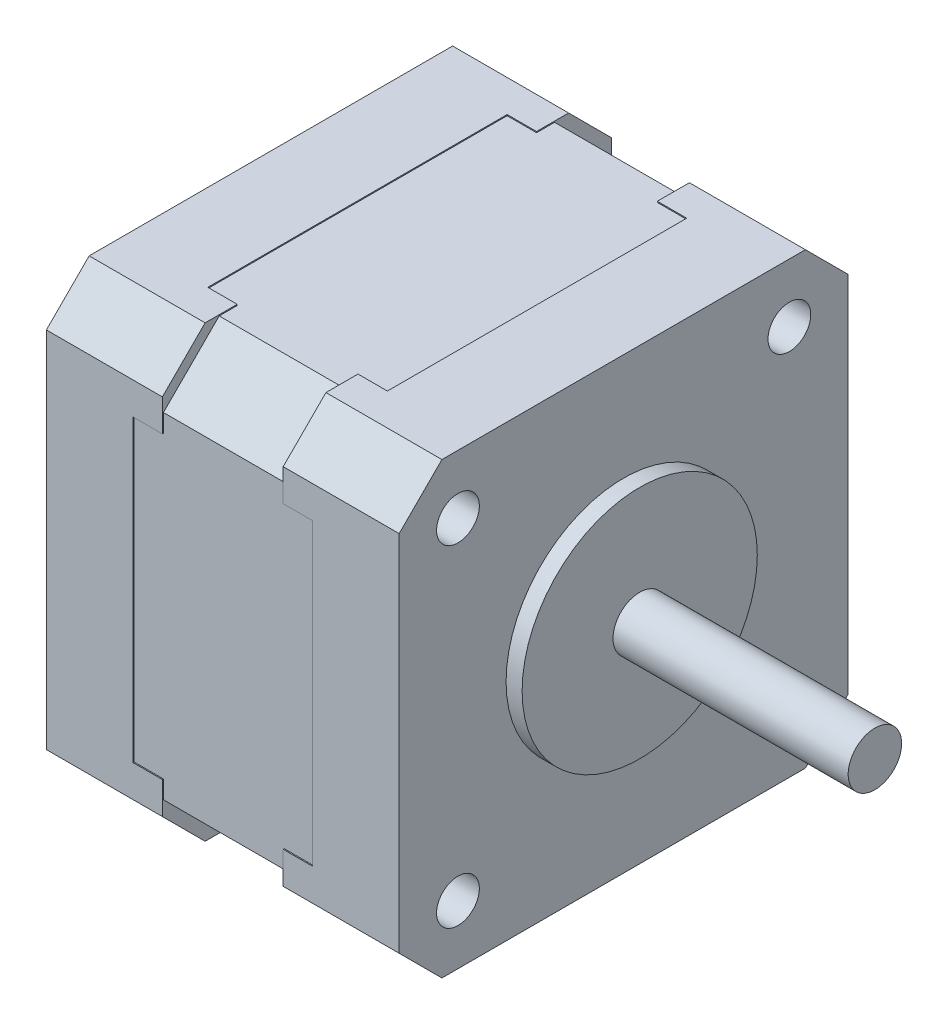
from build123d import *

# Parameters (mm, degrees)
CROQUIS1_W                  = 41.8
CROQUIS1_H                  = 41.8
SALIENTE_EXTRUIR1_DEPTH     = 11.3
CROQUIS2_W                  = 42
CROQUIS2_H                  = 41.9
SALIENTE_EXTRUIR2_DEPTH     = 10.85
CROQUIS3_W                  = 10.85
CROQUIS3_H                  = 42
SALIENTE_EXTRUIR3_DEPTH     = 0.1
CROQUIS4_W                  = 42
CROQUIS4_H                  = 42
SALIENTE_EXTRUIR4_DEPTH     = 10.85
CORTAR_EXTRUIR1_REACH       = 26.9
CROQUIS5_W                  = 0.1
CROQUIS5_H                  = 28
CORTAR_EXTRUIR2_REACH       = 26.9
CROQUIS6_W                  = 28
CROQUIS6_H                  = 0.1
CROQUIS7_W                  = 2.75
CROQUIS7_H                  = 28
CORTAR_EXTRUIR3_DEPTH       = 0.1
CROQUIS8_W                  = 2.75
CROQUIS8_H                  = 28
CORTAR_EXTRUIR4_DEPTH       = 0.1
CROQUIS9_W                  = 28
CROQUIS9_H                  = 0.1
CORTAR_EXTRUIR5_DEPTH       = 2.75
CROQUIS10_W                 = 2.75
CROQUIS10_H                 = 28
CORTAR_EXTRUIR6_DEPTH       = 0.1
CROQUIS11_W                 = 2.75
CROQUIS11_H                 = 28
CORTAR_EXTRUIR7_DEPTH       = 0.1
CROQUIS12_W                 = 2.75
CROQUIS12_H                 = 28
CORTAR_EXTRUIR8_DEPTH       = 0.1
CHAFL_N1_SIZE               = 5.214213562
CHAFL_N2_SIZE               = 4
CROQUIS18_R                 = 2
CORTAR_EXTRUIR10_DEPTH      = 6
CORTAR_EXTRUIR10_DEPTH_BACK = 3


with BuildPart() as part:
    # Croquis1 → Saliente-Extruir1 (new body)
    with BuildSketch(Plane(origin=(-5.65, 0, 0), x_dir=(0, -1, 0), z_dir=(-1, 0, 0))):
        Rectangle(CROQUIS1_W, CROQUIS1_H)
    extrude(amount=-SALIENTE_EXTRUIR1_DEPTH)

    # Croquis2 → Saliente-Extruir2 (add)
    with BuildSketch(Plane(origin=(5.65, 0, 0), x_dir=(0, 0, -1), z_dir=(1, 0, 0))):
        with Locations((0, -0.05)):
            Rectangle(CROQUIS2_W, CROQUIS2_H)
    extrude(amount=SALIENTE_EXTRUIR2_DEPTH)

    # Croquis3 → Saliente-Extruir3 (add)
    with BuildSketch(Plane(origin=(0, 20.9, 0), x_dir=(-1, 0, 0), z_dir=(0, 1, 0))):
        with Locations((-11.075, 0)):
            Rectangle(CROQUIS3_W, CROQUIS3_H)
    extrude(amount=SALIENTE_EXTRUIR3_DEPTH)

    # Croquis4 → Saliente-Extruir4 (add)
    with BuildSketch(Plane(origin=(-5.65, 0, 0), x_dir=(0, 0, -1), z_dir=(1, 0, 0))):
        Rectangle(CROQUIS4_W, CROQUIS4_H)
    extrude(amount=-SALIENTE_EXTRUIR4_DEPTH)

    # Croquis5 → Cortar-Extruir1 (cut, up to next)
    with BuildSketch(Plane(origin=(8.4, 0, 0), x_dir=(0, 0, -1), z_dir=(1, 0, 0)), mode=Mode.PRIVATE) as cortar_extruir1_sk1:
        with Locations((20.95, 0)):
            Rectangle(CROQUIS5_W, CROQUIS5_H)
    cortar_extruir1_tool1 = extrude(cortar_extruir1_sk1.sketch, amount=-CORTAR_EXTRUIR1_REACH, mode=Mode.PRIVATE) & part.part
    add(cortar_extruir1_tool1.solids().sort_by_distance((8.4, 0, -20.95))[0], mode=Mode.SUBTRACT)

    # Croquis6 → Cortar-Extruir2 (cut, up to next)
    with BuildSketch(Plane(origin=(-8.4, 0, 0), x_dir=(0, -1, 0), z_dir=(-1, 0, 0)), mode=Mode.PRIVATE) as cortar_extruir2_sk1:
        with Locations((0, 20.95)):
            Rectangle(CROQUIS6_W, CROQUIS6_H)
    cortar_extruir2_tool1 = extrude(cortar_extruir2_sk1.sketch, amount=-CORTAR_EXTRUIR2_REACH, mode=Mode.PRIVATE) & part.part
    add(cortar_extruir2_tool1.solids().sort_by_distance((-8.4, 0, 20.95))[0], mode=Mode.SUBTRACT)

    # Croquis7 → Cortar-Extruir3 (cut)
    with BuildSketch(Plane.XZ.offset(21)):
        with Locations((7.025, 0)):
            Rectangle(CROQUIS7_W, CROQUIS7_H)
    extrude(amount=-CORTAR_EXTRUIR3_DEPTH, mode=Mode.SUBTRACT)

    # Croquis8 → Cortar-Extruir4 (cut)
    with BuildSketch(Plane.XY.offset(21)):
        with Locations((7.025, 0)):
            Rectangle(CROQUIS8_W, CROQUIS8_H)
    extrude(amount=-CORTAR_EXTRUIR4_DEPTH, mode=Mode.SUBTRACT)

    # Croquis9 → Cortar-Extruir5 (cut)
    with BuildSketch(Plane.ZY.offset(-5.65)):
        with Locations((0, 20.95)):
            Rectangle(CROQUIS9_W, CROQUIS9_H)
    extrude(amount=-CORTAR_EXTRUIR5_DEPTH, mode=Mode.SUBTRACT)

    # Croquis10 → Cortar-Extruir6 (cut)
    with BuildSketch(Plane.XZ.offset(21)):
        with Locations((-7.025, 0)):
            Rectangle(CROQUIS10_W, CROQUIS10_H)
    extrude(amount=-CORTAR_EXTRUIR6_DEPTH, mode=Mode.SUBTRACT)

    # Croquis11 → Cortar-Extruir7 (cut)
    with BuildSketch(Plane(origin=(0, 0, -21), x_dir=(-1, 0, 0), z_dir=(0, 0, -1))):
        with Locations((7.025, 0)):
            Rectangle(CROQUIS11_W, CROQUIS11_H)
    extrude(amount=-CORTAR_EXTRUIR7_DEPTH, mode=Mode.SUBTRACT)

    # Croquis12 → Cortar-Extruir8 (cut)
    with BuildSketch(Plane(origin=(0, 21, 0), x_dir=(-1, 0, 0), z_dir=(0, 1, 0))):
        with Locations((7.025, 0)):
            Rectangle(CROQUIS12_W, CROQUIS12_H)
    extrude(amount=-CORTAR_EXTRUIR8_DEPTH, mode=Mode.SUBTRACT)

    # Croquis15 → Revolución1 (revolve)
    with BuildSketch(Plane.XY):
        Polygon((15.5, 11), (15.5, 0), (40, 0), (40, 2.5), (18, 2.5), (18, 11), align=None)
    revolve(axis=Axis((15.5, 0, 0), (1, 0, 0)))

    # Chaflán1
    chafl_n1_edges = [part.edges().sort_by_distance(p)[0] for p in [
        (0, -20.9, -20.9),
        (0, 20.9, 20.9),
        (0, 20.9, -20.9),
        (0, -20.9, 20.9),
    ]]
    chamfer(chafl_n1_edges, length=CHAFL_N1_SIZE)

    # Chaflán2
    chafl_n2_edges = [part.edges().sort_by_distance(p)[0] for p in [
        (11.075, -21, 21),
        (11.075, -21, -21),
        (11.075, 21, 21),
        (11.075, 21, -21),
        (-11.075, 21, -21),
        (-11.075, -21, -21),
        (-11.075, -21, 21),
        (-11.075, 21, 21),
    ]]
    chamfer(chafl_n2_edges, length=CHAFL_N2_SIZE)

    # Croquis18 → Cortar-Extruir10 (cut, two sides)
    with BuildSketch(Plane(origin=(12.45, 0, 0), x_dir=(0, 0, -1), z_dir=(1, 0, 0))) as cortar_extruir10_sk:
        with Locations((-15.5, 15.5)):
            Circle(CROQUIS18_R)
        with Locations((15.5, 15.5)):
            Circle(CROQUIS18_R)
        with Locations((15.5, -15.5)):
            Circle(CROQUIS18_R)
        with Locations((-15.5, -15.5)):
            Circle(CROQUIS18_R)
    extrude(amount=CORTAR_EXTRUIR10_DEPTH, mode=Mode.SUBTRACT)
    extrude(cortar_extruir10_sk.sketch, amount=-CORTAR_EXTRUIR10_DEPTH_BACK, mode=Mode.SUBTRACT)


solid = part.part
